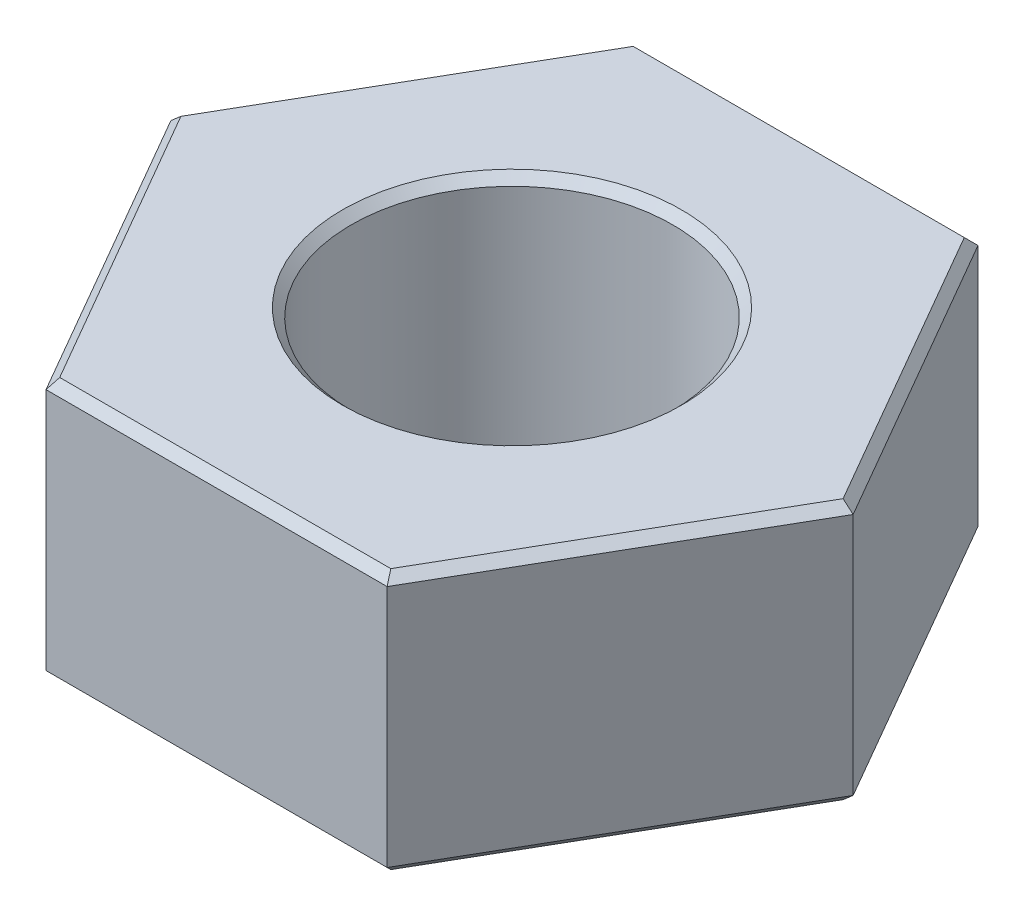
from build123d import *

# Parameters (mm, degrees)
SKETCH_1_R      = 1.85
EXTRUDE_1_DEPTH = 3
CHAMFER_1_SIZE  = 0.1


with BuildPart() as part:
    # Эскиз1 → Бобышка-Вытянуть1 (new body)
    with BuildSketch(Plane(origin=(0, 0, 0), x_dir=(1, 0, 0), z_dir=(0, 1, 0))):
        Polygon((3.92598183, 0), (1.962990915, 3.4), (-1.962990915, 3.4), (-3.92598183, 0), (-1.962990915, -3.4), (1.962990915, -3.4), align=None)
        Circle(SKETCH_1_R, mode=Mode.SUBTRACT)
    extrude(amount=EXTRUDE_1_DEPTH)

    # Фаска1
    chamfer_1_edges = [part.edges().sort_by_distance(p)[0] for p in [
        (0, 3, -3.4),
        (-2.944486373, 3, -1.7),
        (-2.944486373, 3, 1.7),
        (-1.85, 0, 0),
        (-1.85, 3, 0),
        (0, 3, 3.4),
        (2.944486373, 3, 1.7),
        (0, 0, 3.4),
        (-2.944486373, 0, 1.7),
        (-2.944486373, 0, -1.7),
        (2.944486373, 3, -1.7),
        (0, 0, -3.4),
        (2.944486373, 0, -1.7),
        (2.944486373, 0, 1.7),
    ]]
    chamfer(chamfer_1_edges, length=CHAMFER_1_SIZE)


solid = part.part
